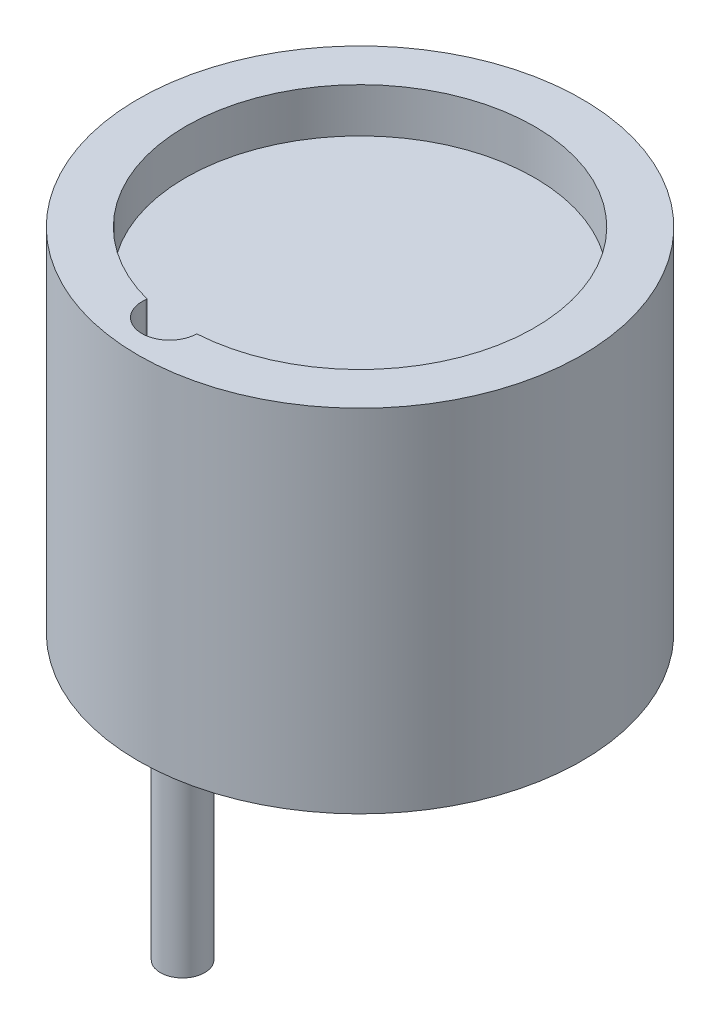
from build123d import *

# Parameters (mm, degrees)
SKETCH1_R           = 6
BOSS_EXTRUDE1_DEPTH = 9.5
CUT_EXTRUDE1_DEPTH  = 1.2
SKETCH3_R           = 0.6
BOSS_EXTRUDE3_DEPTH = 6
SKETCH4_R           = 0.6
BOSS_EXTRUDE4_DEPTH = 4


with BuildPart() as part:
    # Sketch1 → Boss-Extrude1 (new body)
    with BuildSketch(Plane(origin=(0, 0, 0), x_dir=(1, 0, 0), z_dir=(0, 1, 0))):
        Circle(SKETCH1_R)
    extrude(amount=-BOSS_EXTRUDE1_DEPTH)

    # Sketch2 → Cut-Extrude1 (cut)
    with BuildSketch(Plane(origin=(0, 0, 0), x_dir=(1, 0, 0), z_dir=(0, 1, 0))):
        with BuildLine():
            Line((0.296610857, -4.708373641), (0.285073514, -4.794679689))
            ThreePointArc((0.285073514, -4.794679689), (-0.554937351, -5.436588397), (-1.19684606, -4.596577532))
            Line((-1.19684606, -4.596577532), (-1.192556618, -4.56449001))
            ThreePointArc((-1.192556618, -4.56449001), (0.453712824, 4.695839117), (0.296610857, -4.708373641))
        make_face()
    extrude(amount=-CUT_EXTRUDE1_DEPTH, mode=Mode.SUBTRACT)


with BuildPart() as body_2:
    # Sketch3 → Boss-Extrude3 (new body)
    with BuildSketch(Plane.XZ.offset(9.5)):
        with Locations((-0.73871062, 4.060638166)):
            Circle(SKETCH3_R)
    extrude(amount=BOSS_EXTRUDE3_DEPTH)


with BuildPart() as body_3:
    # Sketch4 → Boss-Extrude4 (new body)
    with BuildSketch(Plane.XZ.offset(9.5)):
        with Locations((0.442722745, -4.595156766)):
            Circle(SKETCH4_R)
    extrude(amount=BOSS_EXTRUDE4_DEPTH)


solid = Compound([part.part, body_2.part, body_3.part])
